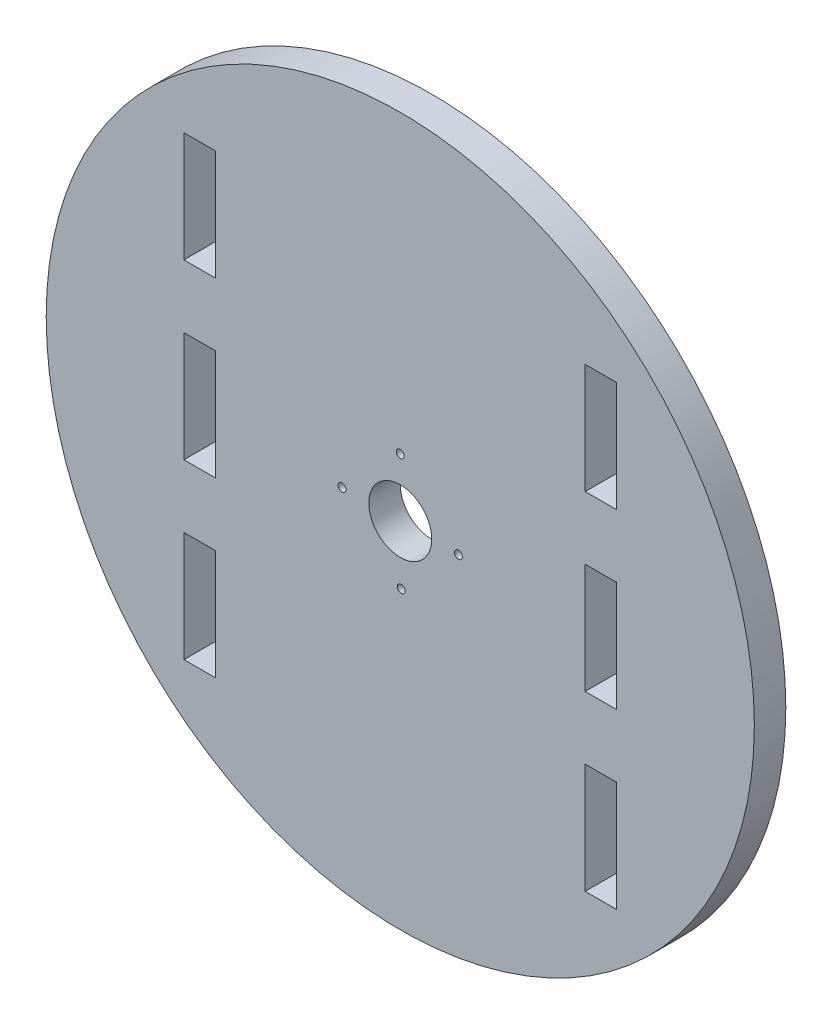
from build123d import *

# Parameters (mm, degrees)
SKETCH1_R           = 45
SKETCH1_R_2         = 0.5
SKETCH1_R_3         = 4
SKETCH1_W           = 4
SKETCH1_H           = 14
BOSS_EXTRUDE1_DEPTH = 4


with BuildPart() as part:
    # Sketch1 → Boss-Extrude1 (new body)
    with BuildSketch(Plane.XY):
        with Locations((45, 45)):
            Circle(SKETCH1_R)
        with Locations((37.6, 45)):
            Circle(SKETCH1_R_2, mode=Mode.SUBTRACT)
        with Locations((52.4, 45)):
            Circle(SKETCH1_R_2, mode=Mode.SUBTRACT)
        with Locations((45.121025162, 37.600989734)):
            Circle(SKETCH1_R_2, mode=Mode.SUBTRACT)
        with Locations((45, 52.4)):
            Circle(SKETCH1_R_2, mode=Mode.SUBTRACT)
        with Locations((45, 45)):
            Circle(SKETCH1_R_3, mode=Mode.SUBTRACT)
        with Locations((19.5, 67)):
            Rectangle(SKETCH1_W, SKETCH1_H, mode=Mode.SUBTRACT)
        with Locations((70.5, 45)):
            Rectangle(SKETCH1_W, SKETCH1_H, mode=Mode.SUBTRACT)
        with Locations((70.5, 23)):
            Rectangle(SKETCH1_W, SKETCH1_H, mode=Mode.SUBTRACT)
        with Locations((19.5, 45)):
            Rectangle(SKETCH1_W, SKETCH1_H, mode=Mode.SUBTRACT)
        with Locations((19.5, 23)):
            Rectangle(SKETCH1_W, SKETCH1_H, mode=Mode.SUBTRACT)
        with Locations((70.5, 67)):
            Rectangle(SKETCH1_W, SKETCH1_H, mode=Mode.SUBTRACT)
    extrude(amount=BOSS_EXTRUDE1_DEPTH)


solid = part.part
